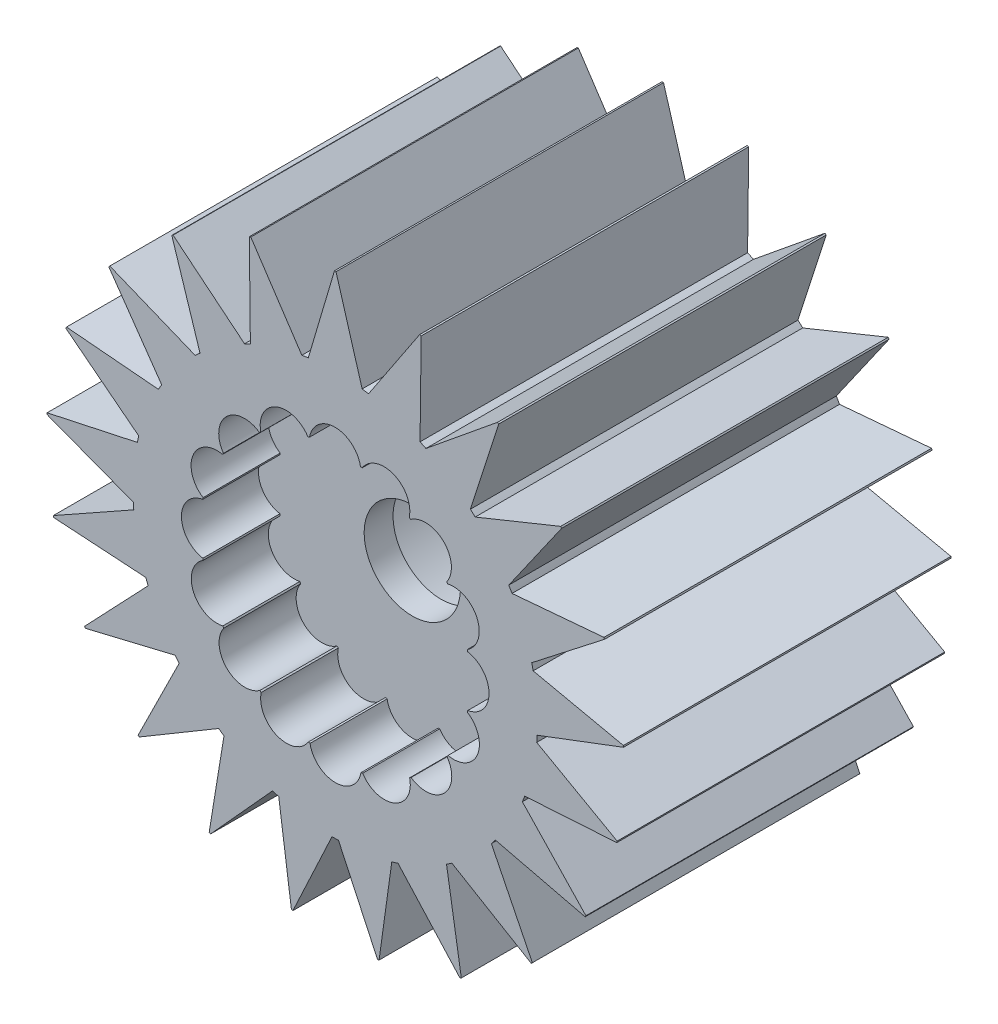
from build123d import *

# Parameters (mm, degrees)
EXTRUDE_1_DEPTH          = 4.25
SKETCH_2_R               = 1.25
CUT_EXTRUDE_1_DEPTH      = 5.25
CUT_EXTRUDE_1_DEPTH_BACK = 5.25
SKETCH_3_R               = 3
CUT_EXTRUDE_2_DEPTH      = 1.5
CUT_EXTRUDE_2_DEPTH_BACK = 10
CUT_EXTRUDE_7_DEPTH      = 2


with BuildPart() as part:
    # 草图1 → 凸台-拉伸1 (new body, symmetric)
    with BuildSketch(Plane.XY):
        with BuildLine():
            Line((-0.02, 7.499973333), (-0.7, 5.203124062))
            ThreePointArc((-0.7, 5.203124062), (-0.783248757, 5.191244686), (-0.866296562, 5.178033436))
            Line((-0.866296562, 5.178033436), (-2.191544492, 7.172665665))
            ThreePointArc((-2.191544492, 7.172665665), (-2.210663808, 7.166796043), (-2.229767404, 7.160875458))
            Line((-2.229767404, 7.160875458), (-2.202548704, 4.765635236))
            ThreePointArc((-2.202548704, 4.765635236), (-2.278597445, 4.729745626), (-2.354061585, 4.692642545))
            Line((-2.354061585, 4.692642545), (-4.208360638, 6.208035175))
            ThreePointArc((-4.208360638, 6.208035175), (-4.224900435, 6.196790807), (-4.241410189, 6.185502373))
            Line((-4.241410189, 6.185502373), (-3.50939129, 3.904698807))
            ThreePointArc((-3.50939129, 3.904698807), (-3.57148275, 3.847987911), (-3.632657906, 3.79028977))
            Line((-3.632657906, 3.79028977), (-5.851245474, 4.691793517))
            ThreePointArc((-5.851245474, 4.691793517), (-5.863736119, 4.676173514), (-5.876185066, 4.660520258))
            Line((-5.876185066, 4.660520258), (-4.50440906, 2.696812752))
            ThreePointArc((-4.50440906, 2.696812752), (-4.54702614, 2.624319584), (-4.58847663, 2.551153116))
            Line((-4.58847663, 2.551153116), (-6.974221471, 2.758665415))
            ThreePointArc((-6.974221471, 2.758665415), (-6.981553115, 2.740057683), (-6.988835112, 2.721430465))
            Line((-6.988835112, 2.721430465), (-5.099190317, 1.249303051))
            ThreePointArc((-5.099190317, 1.249303051), (-5.118546304, 1.167468945), (-5.136589069, 1.085335312))
            Line((-5.136589069, 1.085335312), (-7.477507285, 0.580417785))
            ThreePointArc((-7.477507285, 0.580417785), (-7.479028479, 0.560475702), (-7.480496489, 0.540529633))
            Line((-7.480496489, 0.540529633), (-5.240886137, -0.30921271))
            ThreePointArc((-5.240886137, -0.30921271), (-5.235261165, -0.393116433), (-5.228293028, -0.476919298))
            Line((-5.228293028, -0.476919298), (-7.316383762, -1.649402513))
            ThreePointArc((-7.316383762, -1.649402513), (-7.311959341, -1.668907005), (-7.307482925, -1.688399629))
            Line((-7.307482925, -1.688399629), (-4.916906224, -1.840253564))
            ThreePointArc((-4.916906224, -1.840253564), (-4.886800098, -1.918771691), (-4.855440207, -1.996797535))
            Line((-4.855440207, -1.996797535), (-6.505167434, -3.732666159))
            ThreePointArc((-6.505167434, -3.732666159), (-6.495190528, -3.75), (-6.485167434, -3.767307175))
            Line((-6.485167434, -3.767307175), (-4.156037616, -3.207779813))
            ThreePointArc((-4.156037616, -3.207779813), (-4.104125397, -3.273935664), (-4.051160216, -3.339251548))
            Line((-4.051160216, -3.339251548), (-5.115938433, -5.484266036))
            ThreePointArc((-5.115938433, -5.484266036), (-5.101295533, -5.497889039), (-5.086616358, -5.511472945))
            Line((-5.086616358, -5.511472945), (-3.025886828, -4.290280749))
            ThreePointArc((-3.025886828, -4.290280749), (-2.956781143, -4.338196085), (-2.886916862, -4.384998407))
            Line((-2.886916862, -4.384998407), (-3.27213585, -6.748564809))
            ThreePointArc((-3.27213585, -6.748564809), (-3.254128043, -6.757266509), (-3.236097096, -6.765920158))
            Line((-3.236097096, -6.765920158), (-1.626872715, -4.991571413))
            ThreePointArc((-1.626872715, -4.991571413), (-1.546713909, -5.016988747), (-1.466158276, -5.041118915))
            Line((-1.466158276, -5.041118915), (-1.137589638, -7.413223982))
            ThreePointArc((-1.137589638, -7.413223982), (-1.117816996, -7.416231197), (-1.098036405, -7.419185673))
            Line((-1.098036405, -7.419185673), (-0.083303823, -5.249339051))
            ThreePointArc((-0.083303823, -5.249339051), (0.000785643, -5.249999941), (0.084874907, -5.249313884))
            Line((0.084874907, -5.249313884), (1.098036405, -7.419185673))
            ThreePointArc((1.098036405, -7.419185673), (1.117816996, -7.416231197), (1.137589638, -7.413223982))
            Line((1.137589638, -7.413223982), (1.46766698, -5.040679878))
            ThreePointArc((1.46766698, -5.040679878), (1.548215387, -5.016525602), (1.628366583, -4.991084278))
            Line((1.628366583, -4.991084278), (3.236097096, -6.765920158))
            ThreePointArc((3.236097096, -6.765920158), (3.254128043, -6.757266509), (3.27213585, -6.748564809))
            Line((3.27213585, -6.748564809), (2.88822913, -4.384134178))
            ThreePointArc((2.88822913, -4.384134178), (2.9580794, -4.337310948), (3.027170741, -4.289374931))
            Line((3.027170741, -4.289374931), (5.086616358, -5.511472945))
            ThreePointArc((5.086616358, -5.511472945), (5.101295533, -5.497889039), (5.115938433, -5.484266036))
            Line((5.115938433, -5.484266036), (4.052159448, -3.338038916))
            ThreePointArc((4.052159448, -3.338038916), (4.105105077, -3.272707183), (4.156997495, -3.206535799))
            Line((4.156997495, -3.206535799), (6.485167434, -3.767307175))
            ThreePointArc((6.485167434, -3.767307175), (6.495190528, -3.75), (6.505167434, -3.732666159))
            Line((6.505167434, -3.732666159), (4.856037616, -1.995344248))
            ThreePointArc((4.856037616, -1.995344248), (4.887374153, -1.917309022), (4.917456778, -1.838781888))
            Line((4.917456778, -1.838781888), (7.307482925, -1.688399629))
            ThreePointArc((7.307482925, -1.688399629), (7.311959341, -1.668907005), (7.316383762, -1.649402513))
            Line((7.316383762, -1.649402513), (5.228435532, -0.475354487))
            ThreePointArc((5.228435532, -0.475354487), (5.235378588, -0.391549541), (5.240978447, -0.307644138))
            Line((5.240978447, -0.307644138), (7.480496489, 0.540529633))
            ThreePointArc((7.480496489, 0.540529633), (7.479028479, 0.560475702), (7.477507285, 0.580417785))
            Line((7.477507285, 0.580417785), (5.136264006, 1.086872606))
            ThreePointArc((5.136264006, 1.086872606), (5.11819666, 1.169000836), (5.098816181, 1.250829144))
            Line((5.098816181, 1.250829144), (6.988835112, 2.721430465))
            ThreePointArc((6.988835112, 2.721430465), (6.981553115, 2.740057683), (6.974221471, 2.758665415))
            Line((6.974221471, 2.758665415), (4.587712883, 2.552526299))
            ThreePointArc((4.587712883, 2.552526299), (4.546240497, 2.625680357), (4.503601722, 2.698160768))
            Line((4.503601722, 2.698160768), (5.876185066, 4.660520258))
            ThreePointArc((5.876185066, 4.660520258), (5.863736119, 4.676173514), (5.851245474, 4.691793517))
            Line((5.851245474, 4.691793517), (3.631523337, 3.791376828))
            ThreePointArc((3.631523337, 3.791376828), (3.570330916, 3.849056657), (3.508222486, 3.905748967))
            Line((3.508222486, 3.905748967), (4.241410189, 6.185502373))
            ThreePointArc((4.241410189, 6.185502373), (4.224900435, 6.196790807), (4.208360638, 6.208035175))
            Line((4.208360638, 6.208035175), (2.352657006, 4.693346888))
            ThreePointArc((2.352657006, 4.693346888), (2.277181765, 4.730427381), (2.201122286, 4.766294229))
            Line((2.201122286, 4.766294229), (2.229767404, 7.160875458))
            ThreePointArc((2.229767404, 7.160875458), (2.210663808, 7.166796043), (2.191544492, 7.172665665))
            Line((2.191544492, 7.172665665), (0.864746776, 5.17829248))
            ThreePointArc((0.864746776, 5.17829248), (0.781695021, 5.191478874), (0.698442712, 5.203333333))
            Line((0.698442712, 5.203333333), (0.02, 7.499973333))
            ThreePointArc((0.02, 7.499973333), (0, 7.5), (-0.02, 7.499973333))
        make_face()
    extrude(amount=EXTRUDE_1_DEPTH, both=True)

    # 草图2 → 切除-拉伸1 (cut, two sides)
    with BuildSketch(Plane.XY) as cut_extrude_1_sk:
        Circle(SKETCH_2_R)
    extrude(amount=CUT_EXTRUDE_1_DEPTH, mode=Mode.SUBTRACT)
    extrude(cut_extrude_1_sk.sketch, amount=-CUT_EXTRUDE_1_DEPTH_BACK, mode=Mode.SUBTRACT)

    # 草图3 → 切除-拉伸2 (cut, two sides)
    with BuildSketch(Plane.XY) as cut_extrude_2_sk:
        Circle(SKETCH_3_R)
    extrude(amount=CUT_EXTRUDE_2_DEPTH, mode=Mode.SUBTRACT)
    extrude(cut_extrude_2_sk.sketch, amount=-CUT_EXTRUDE_2_DEPTH_BACK, mode=Mode.SUBTRACT)

    # 草图8 → 切除-拉伸7 (cut)
    with BuildSketch(Plane.XY.offset(4.25)):
        with BuildLine():
            ThreePointArc((-0.667710572, 3.435718643), (-0.68946688, 3.431418864), (-0.711195507, 3.426981318))
            ThreePointArc((-0.711195507, 3.426981318), (-1.534825288, 3.685181388), (-1.931676734, 2.91866836))
            ThreePointArc((-1.931676734, 2.91866836), (-1.950131488, 2.906370104), (-1.968507946, 2.89395516))
            ThreePointArc((-1.968507946, 2.89395516), (-2.828251532, 2.817311449), (-2.901562624, 1.957277277))
            ThreePointArc((-2.901562624, 1.957277277), (-2.913906254, 1.938852842), (-2.926132894, 1.920350563))
            ThreePointArc((-2.926132894, 1.920350563), (-3.691102118, 1.52053138), (-3.429711907, 0.697908472))
            ThreePointArc((-3.429711907, 0.697908472), (-3.434065208, 0.67616281), (-3.438280635, 0.654390001))
            ThreePointArc((-3.438280635, 0.654390001), (-3.992015867, -0.007735807), (-3.435718643, -0.667710572))
            ThreePointArc((-3.435718643, -0.667710572), (-3.431418864, -0.68946688), (-3.426981318, -0.711195507))
            ThreePointArc((-3.426981318, -0.711195507), (-3.685181388, -1.534825288), (-2.91866836, -1.931676734))
            ThreePointArc((-2.91866836, -1.931676734), (-2.906370104, -1.950131488), (-2.89395516, -1.968507946))
            ThreePointArc((-2.89395516, -1.968507946), (-2.817311449, -2.828251532), (-1.957277277, -2.901562624))
            ThreePointArc((-1.957277277, -2.901562624), (-1.938852842, -2.913906254), (-1.920350563, -2.926132894))
            ThreePointArc((-1.920350563, -2.926132894), (-1.52053138, -3.691102118), (-0.697908472, -3.429711907))
            ThreePointArc((-0.697908472, -3.429711907), (-0.67616281, -3.434065208), (-0.654390001, -3.438280635))
            ThreePointArc((-0.654390001, -3.438280635), (0.007735807, -3.992015867), (0.667710572, -3.435718643))
            ThreePointArc((0.667710572, -3.435718643), (0.68946688, -3.431418864), (0.711195507, -3.426981318))
            ThreePointArc((0.711195507, -3.426981318), (1.534825288, -3.685181388), (1.931676734, -2.91866836))
            ThreePointArc((1.931676734, -2.91866836), (1.950131488, -2.906370104), (1.968507946, -2.89395516))
            ThreePointArc((1.968507946, -2.89395516), (2.828251532, -2.817311449), (2.901562624, -1.957277277))
            ThreePointArc((2.901562624, -1.957277277), (2.913906254, -1.938852842), (2.926132894, -1.920350563))
            ThreePointArc((2.926132894, -1.920350563), (3.691102118, -1.52053138), (3.429711907, -0.697908472))
            ThreePointArc((3.429711907, -0.697908472), (3.434065208, -0.67616281), (3.438280635, -0.654390001))
            ThreePointArc((3.438280635, -0.654390001), (3.992015867, 0.007735807), (3.435718643, 0.667710572))
            ThreePointArc((3.435718643, 0.667710572), (3.431418864, 0.68946688), (3.426981318, 0.711195507))
            ThreePointArc((3.426981318, 0.711195507), (3.685181388, 1.534825288), (2.91866836, 1.931676734))
            ThreePointArc((2.91866836, 1.931676734), (2.906370104, 1.950131488), (2.89395516, 1.968507946))
            ThreePointArc((2.89395516, 1.968507946), (2.817311449, 2.828251532), (1.957277277, 2.901562624))
            ThreePointArc((1.957277277, 2.901562624), (1.938852842, 2.913906254), (1.920350563, 2.926132894))
            ThreePointArc((1.920350563, 2.926132894), (1.52053138, 3.691102118), (0.697908472, 3.429711907))
            ThreePointArc((0.697908472, 3.429711907), (0.67616281, 3.434065208), (0.654390001, 3.438280635))
            ThreePointArc((0.654390001, 3.438280635), (-0.007735807, 3.992015867), (-0.667710572, 3.435718643))
        make_face()
    extrude(amount=-CUT_EXTRUDE_7_DEPTH, mode=Mode.SUBTRACT)


solid = part.part
